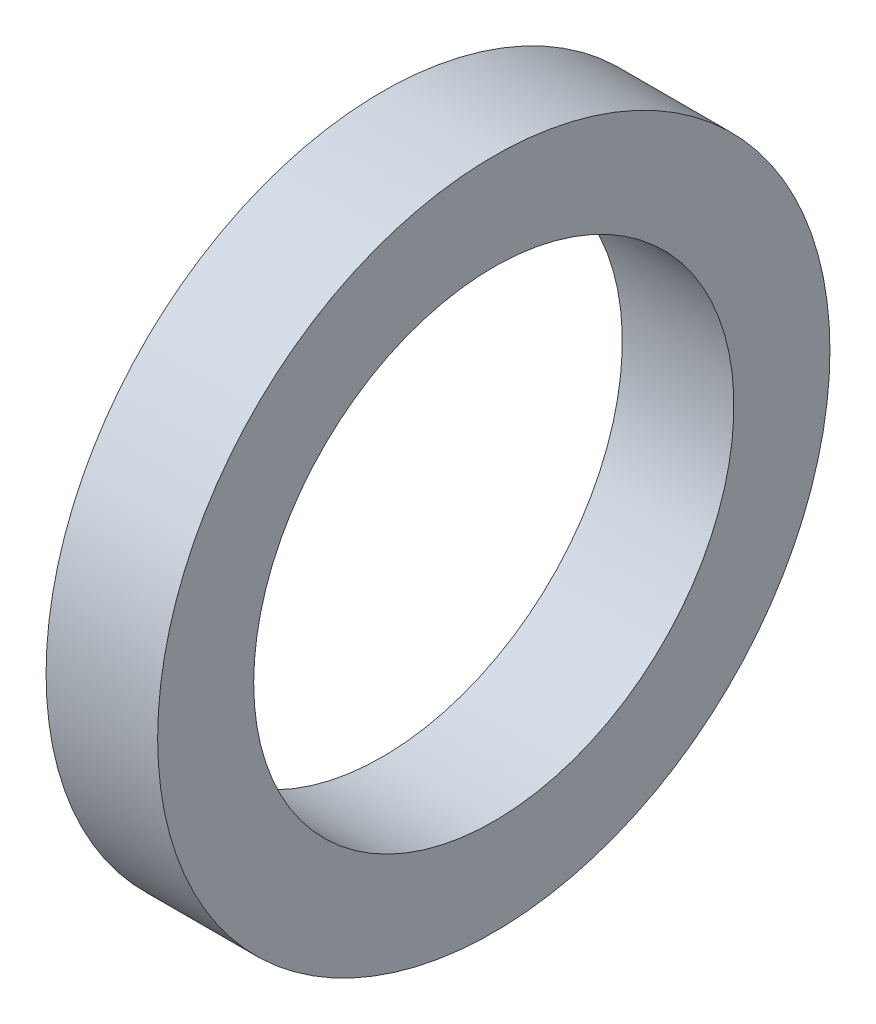
from build123d import *

# Parameters (mm, degrees)
SKETCH3_W = 6.97000003
SKETCH3_H = 6.000000065


with BuildPart() as part:
    # Sketch3 → Revolve1 (revolve)
    with BuildSketch(Plane.XY):
        with Locations((26.424799957, 18.000000005)):
            Rectangle(SKETCH3_W, SKETCH3_H)
    revolve(axis=Axis((0, 0, 0), (1, 0, 0)))


solid = part.part
